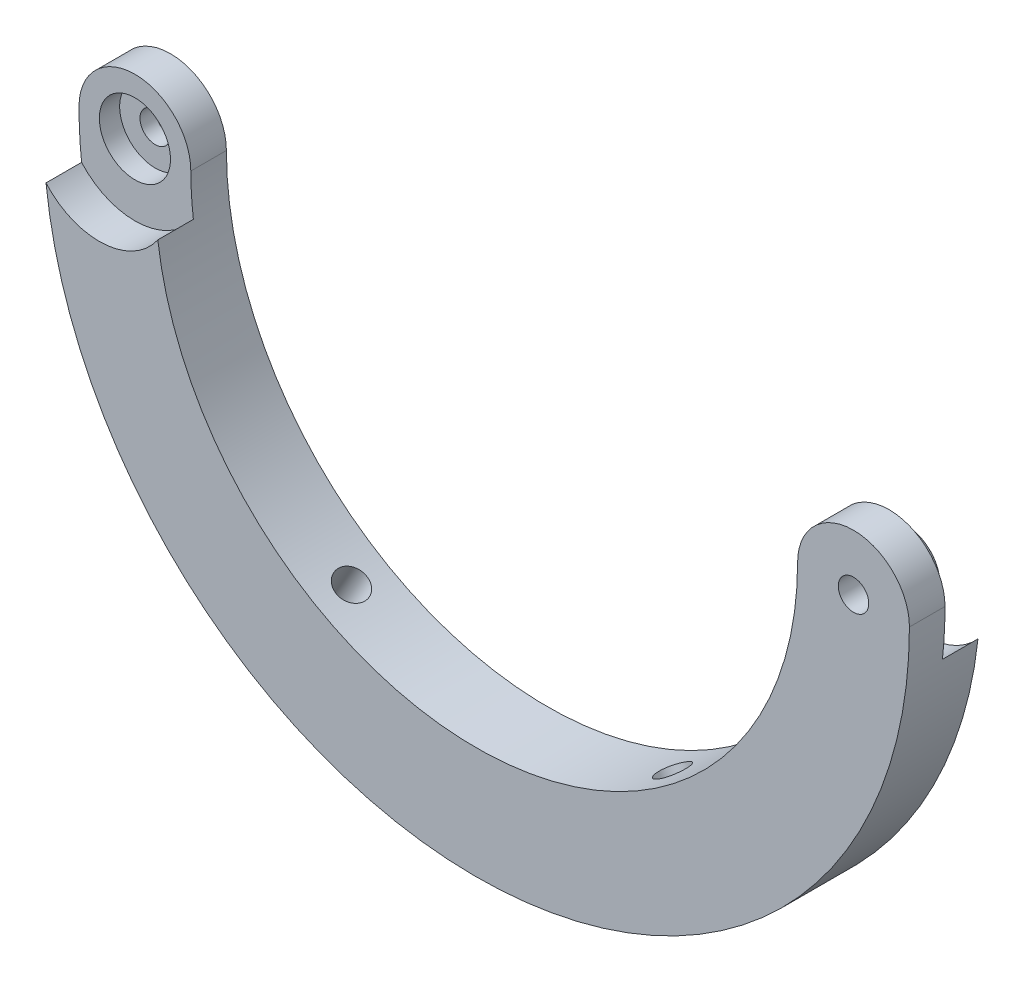
from build123d import *

# Parameters (mm, degrees)
BOSS_EXTRUDE1_DEPTH = 3.5
SKETCH8_R           = 1.5
CUT_EXTRUDE7_DEPTH  = 77.763269239
SKETCH9_R           = 3
CUT_EXTRUDE8_DEPTH  = 7
SKETCH10_R          = 7
CUT_EXTRUDE9_DEPTH  = 61.347079612
SKETCH10_3_R        = 7
CUT_EXTRUDE10_DEPTH = 61.347079612
SKETCH11_R          = 3.5
CUT_EXTRUDE11_DEPTH = 2
SKETCH12_R          = 1.5
CUT_EXTRUDE12_DEPTH = 61.496033078
SKETCH13_R          = 3.5
BOSS_EXTRUDE3_DEPTH = 1.8
SKETCH14_R          = 1.5
CUT_EXTRUDE13_DEPTH = 61.478178032
FILLET1_R           = 0.5


with BuildPart() as part:
    # Sketch1 → Boss-Extrude1 (new, symmetric)
    with BuildSketch(Plane.XY):
        with BuildLine():
            ThreePointArc((-31.6, 0), (0, -31.6), (31.6, 0))
            ThreePointArc((31.6, 0), (37.1, 5.5), (42.6, 0))
            ThreePointArc((42.6, 0), (0, -42.6), (-42.6, 0))
            ThreePointArc((-42.6, 0), (-37.1, 5.5), (-31.6, 0))
        make_face()
    extrude(amount=BOSS_EXTRUDE1_DEPTH, both=True)

    # Sketch8 → Cut-Extrude7 (cut, through all)
    with BuildSketch(Plane(origin=(-21.3, -36.892682201, 0), x_dir=(-0.8660254037844363, 0.5000000000000042, 0), z_dir=(-0.5000000000000041, -0.8660254037844362, 0))):
        Circle(SKETCH8_R)
    cut_extrude7 = extrude(amount=-CUT_EXTRUDE7_DEPTH, mode=Mode.SUBTRACT)

    # Sketch9 → Cut-Extrude8 (cut)
    with BuildSketch(Plane(origin=(-21.3, -36.892682201, 0), x_dir=(-0.8660254037844363, 0.5000000000000042, 0), z_dir=(-0.5000000000000041, -0.8660254037844362, 0))):
        Circle(SKETCH9_R)
    cut_extrude8 = extrude(amount=-CUT_EXTRUDE8_DEPTH, mode=Mode.SUBTRACT)

    # Mirror1: Cut-Extrude7, Cut-Extrude8 across plane
    add(cut_extrude7.mirror(Plane(origin=(0, 0, 0), x_dir=(0, 0, 1), z_dir=(1, 0, 0))), mode=Mode.SUBTRACT)
    add(cut_extrude8.mirror(Plane(origin=(0, 0, 0), x_dir=(0, 0, 1), z_dir=(1, 0, 0))), mode=Mode.SUBTRACT)

    # Sketch10 → Cut-Extrude9 (cut, through all)
    with BuildSketch(Plane.XY):
        with Locations((-37.1, 0)):
            Circle(SKETCH10_R)
    extrude(amount=CUT_EXTRUDE9_DEPTH, mode=Mode.SUBTRACT)

    # Sketch10_3 → Cut-Extrude10 (cut, through all)
    with BuildSketch(Plane.XY):
        with Locations((37.1, 0)):
            Circle(SKETCH10_3_R)
    extrude(amount=-CUT_EXTRUDE10_DEPTH, mode=Mode.SUBTRACT)

    # Sketch11 → Cut-Extrude11 (cut)
    with BuildSketch(Plane.XY):
        with Locations((-37.1, 0)):
            Circle(SKETCH11_R)
    extrude(amount=-CUT_EXTRUDE11_DEPTH, mode=Mode.SUBTRACT)

    # Sketch12 → Cut-Extrude12 (cut, through all)
    with BuildSketch(Plane.XY.offset(-2)):
        with Locations((-37.1, 0)):
            Circle(SKETCH12_R)
    extrude(amount=-CUT_EXTRUDE12_DEPTH, mode=Mode.SUBTRACT)

    # Sketch13 → Boss-Extrude3 (add)
    with BuildSketch(Plane(origin=(0, 0, 0), x_dir=(-1, 0, 0), z_dir=(0, 0, -1))):
        with Locations((-37.1, 0)):
            Circle(SKETCH13_R)
    extrude(amount=BOSS_EXTRUDE3_DEPTH)

    # Sketch14 → Cut-Extrude13 (cut, through all)
    with BuildSketch(Plane(origin=(0, 0, -1.8), x_dir=(-1, 0, 0), z_dir=(0, 0, -1))):
        with Locations((-37.1, 0)):
            Circle(SKETCH14_R)
    extrude(amount=-CUT_EXTRUDE13_DEPTH, mode=Mode.SUBTRACT)

    # Fillet1
    fillet1_edges = [part.edges().sort_by_distance(p)[0] for p in [
        (40.6, 0, -1.8),
    ]]
    fillet(fillet1_edges, radius=FILLET1_R)


solid = part.part
